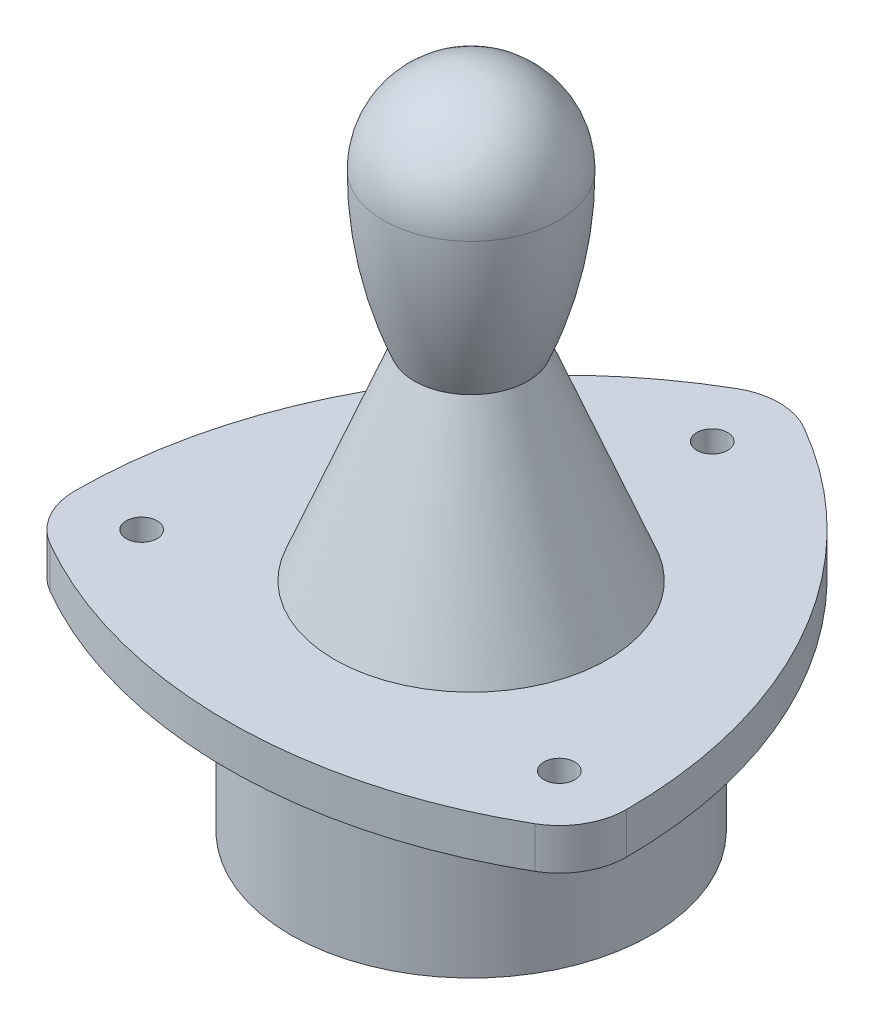
from build123d import *

# Parameters (mm, degrees)
SKETCH_1_R      = 35
EXTRUDE_1_DEPTH = 42
SKETCH_2_R      = 3
EXTRUDE_2_DEPTH = 8


with BuildPart() as part:
    # Эскиз1 → Бобышка-Вытянуть1 (new body)
    with BuildSketch(Plane(origin=(0, 0, 0), x_dir=(1, 0, 0), z_dir=(0, 1, 0))):
        Circle(SKETCH_1_R)
    extrude(amount=EXTRUDE_1_DEPTH)

    # Эскиз2 → Бобышка-Вытянуть2 (add)
    with BuildSketch(Plane(origin=(0, 42, 0), x_dir=(1, 0, 0), z_dir=(0, 1, 0))):
        with BuildLine():
            ThreePointArc((-47, -34.641016151), (0, -47.234628196), (47, -34.641016151))
            ThreePointArc((47, -34.641016151), (51.758330249, -29.882685902), (53.5, -23.382685902))
            ThreePointArc((53.5, -23.382685902), (40.906387956, 23.617314098), (6.5, 58.023702054))
            ThreePointArc((6.5, 58.023702054), (0, 59.765371804), (-6.5, 58.023702054))
            ThreePointArc((-6.5, 58.023702054), (-40.906387956, 23.617314098), (-53.5, -23.382685902))
            ThreePointArc((-53.5, -23.382685902), (-51.758330249, -29.882685902), (-47, -34.641016151))
        make_face()
        with Locations((0, 46.765371804)):
            Circle(SKETCH_2_R, mode=Mode.SUBTRACT)
        with Locations((-40.5, -23.382685902)):
            Circle(SKETCH_2_R, mode=Mode.SUBTRACT)
        with Locations((40.5, -23.382685902)):
            Circle(SKETCH_2_R, mode=Mode.SUBTRACT)
    extrude(amount=-EXTRUDE_2_DEPTH)

    # Эскиз3 → Повернуть1 (revolve)
    with BuildSketch(Plane(origin=(0, 0, 0), x_dir=(0, 0, -1), z_dir=(1, 0, 0))):
        with BuildLine():
            Line((11, 81), (26.5, 42))
            Line((26.5, 42), (0, 42))
            Line((0, 42), (0, 128))
            ThreePointArc((0, 128), (12.02081528, 123.02081528), (17, 111))
            ThreePointArc((17, 111), (15.485292704, 95.702941459), (11, 81))
        make_face()
    revolve(axis=Axis((0, 128, 0), (0, -1, 0)))


solid = part.part
